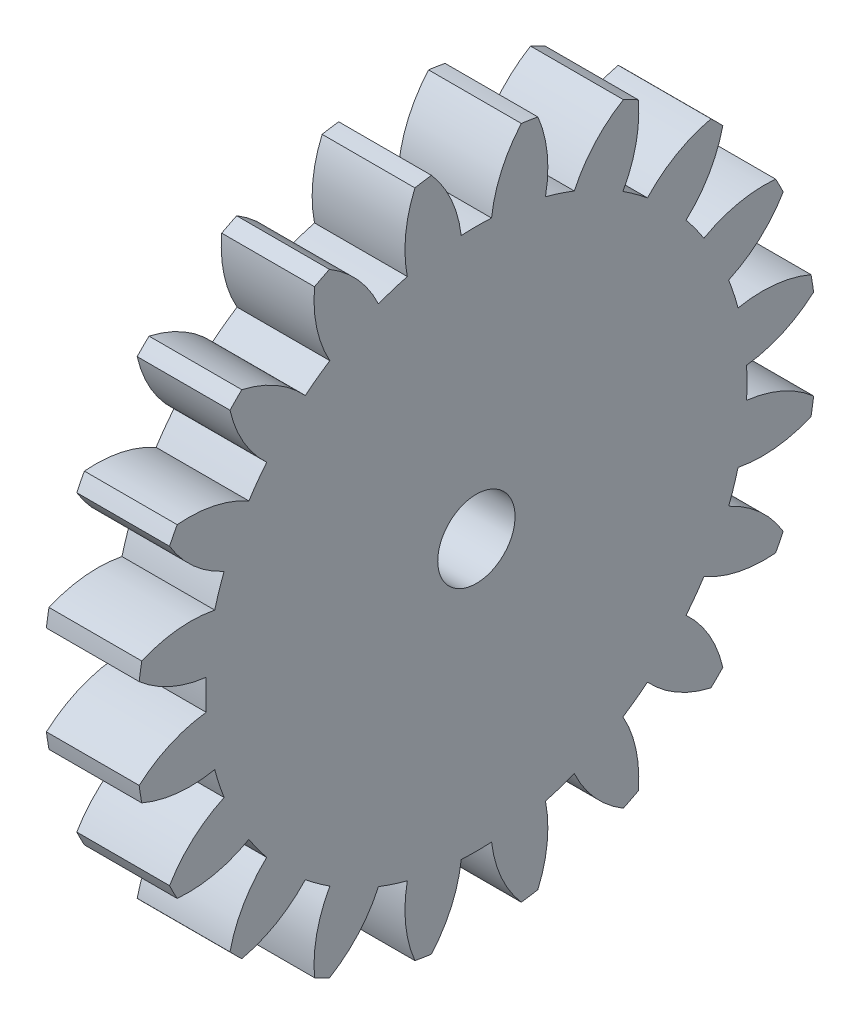
from build123d import *

# Parameters (mm, degrees)
BASPROSKE_W     = 12
BASPROSKE_H     = 44
TOOTHCUT_DEPTH  = 64.371918071
TEETHCUTS_COUNT = 20
TEETHCUTS_ANGLE = 342
BORSKE_R        = 5
BORE_DEPTH      = 50.0000508


with BuildPart() as part:
    # BasProSke → Base-Revolve (revolve)
    with BuildSketch(Plane(origin=(0, 0, 0), x_dir=(1, 0, 0), z_dir=(0, 1, 0)), mode=Mode.PRIVATE) as base_revolve_sk:
        with Locations((6, 22)):
            Rectangle(BASPROSKE_W, BASPROSKE_H)
    revolve(base_revolve_sk.sketch.rotate(Axis((-10, 0, 0), (1, 0, 0)), 180), axis=Axis((-10, 0, 0), (1, 0, 0)))

    # TooCutSke → ToothCut (cut, through all)
    with BuildSketch(Plane(origin=(0, 0, 0), x_dir=(0, 0, -1), z_dir=(1, 0, 0))):
        with BuildLine():
            ThreePointArc((1.961730392, 34.943978235), (0, 34.999), (-1.961730392, 34.943978235))
            ThreePointArc((-1.961730392, 34.943978235), (-3.235659864, 39.585086827), (-5.832115241, 43.637395396))
            ThreePointArc((-5.832115241, 43.637395396), (0, 44.0254), (5.832115241, 43.637395396))
            ThreePointArc((5.832115241, 43.637395396), (3.235659864, 39.585086827), (1.961730392, 34.943978235))
        make_face()
    toothcut = extrude(amount=TOOTHCUT_DEPTH, mode=Mode.SUBTRACT)

    # TeethCuts: ToothCut ×20 about axis
    teethcuts_axis = Axis((-10, 0, 0), (1, 0, 0))
    for i in range(1, TEETHCUTS_COUNT):
        add(toothcut.rotate(teethcuts_axis, i * TEETHCUTS_ANGLE / (TEETHCUTS_COUNT - 1)), mode=Mode.SUBTRACT)

    # BorSke → Bore (cut, symmetric)
    with BuildSketch(Plane(origin=(0, 0, 0), x_dir=(0, 0, -1), z_dir=(1, 0, 0))):
        with Locations(Location((0, 0, 0), (0, 0, 180))):
            Circle(BORSKE_R)
    extrude(amount=BORE_DEPTH, both=True, mode=Mode.SUBTRACT)


solid = part.part
